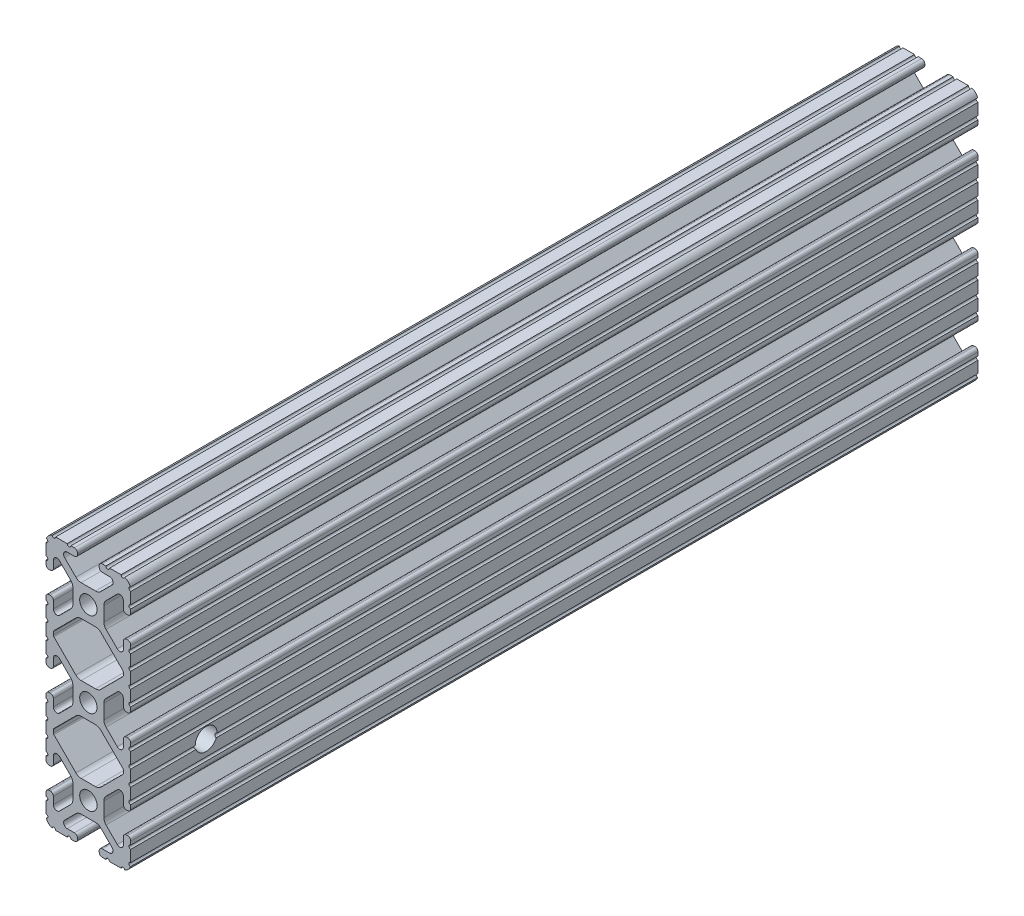
from build123d import *

# Parameters (mm, degrees)
BOSS_EXTRUDE1_DEPTH     = 127
SKETCH5_R               = 0.55245
CUT_EXTRUDE1_DEPTH      = 134.198723718
CUT_EXTRUDE1_DEPTH_BACK = 134.198723718
BOSS_EXTRUDE2_DEPTH     = 127
CUT_EXTRUDE2_DEPTH      = 134.198723718
CUT_EXTRUDE2_DEPTH_BACK = 134.198723718
SKETCH8_R               = 3.2639
CUT_EXTRUDE3_DEPTH      = 136.002851822


with BuildPart() as part:
    # Sketch4 → Boss-Extrude1 (new, symmetric)
    with BuildSketch(Plane.XY):
        with BuildLine():
            Line((4.190365, -38.1), (10.11729625, -38.1))
            ThreePointArc((10.11729625, -38.1), (11.943543585, -37.343543585), (12.7, -35.51729625))
            Line((12.7, -35.51729625), (12.7, -29.590365))
            ThreePointArc((12.7, -29.590365), (12.42492494, -28.92627506), (11.760835, -28.6512))
            Line((11.760835, -28.6512), (11.429365, -28.6512))
            ThreePointArc((11.429365, -28.6512), (10.76527506, -28.92627506), (10.4902, -29.590365))
            Line((10.4902, -29.590365), (10.4902, -31.748478019))
            ThreePointArc((10.4902, -31.748478019), (9.830707141, -32.735478831), (8.666460301, -32.503895736))
            Line((8.666460301, -32.503895736), (5.299899128, -29.137334563))
            ThreePointArc((5.299899128, -29.137334563), (4.817571085, -28.415479634), (4.6482, -27.56399369))
            Line((4.6482, -27.56399369), (4.6482, -25.4))
            Line((4.6482, -25.4), (2.6035, -25.4))
            ThreePointArc((2.6035, -25.4), (1.840952505, -27.240952505), (0, -28.0035))
            Line((0, -28.0035), (0, -30.0482))
            Line((0, -30.0482), (2.16399369, -30.0482))
            ThreePointArc((2.16399369, -30.0482), (3.015479634, -30.217571085), (3.737334563, -30.699899128))
            Line((3.737334563, -30.699899128), (7.103895736, -34.066460301))
            ThreePointArc((7.103895736, -34.066460301), (7.335478831, -35.230707141), (6.348478019, -35.8902))
            Line((6.348478019, -35.8902), (4.190365, -35.8902))
            ThreePointArc((4.190365, -35.8902), (3.52627506, -36.16527506), (3.2512, -36.829365))
            Line((3.2512, -36.829365), (3.2512, -37.160835))
            ThreePointArc((3.2512, -37.160835), (3.52627506, -37.82492494), (4.190365, -38.1))
        make_face()
    extrude(amount=BOSS_EXTRUDE1_DEPTH, both=True)

    # Sketch5 → Cut-Extrude1 (cut, two sides)
    with BuildSketch(Plane.XY) as cut_extrude1_sk:
        with Locations((10.356153152, -38.1)):
            Circle(SKETCH5_R)
        with Locations((5.796028019, -38.1)):
            Circle(SKETCH5_R)
        with Locations((12.7, -35.756153152)):
            Circle(SKETCH5_R)
        with Locations((12.7, -31.196028019)):
            Circle(SKETCH5_R)
    extrude(amount=CUT_EXTRUDE1_DEPTH, mode=Mode.SUBTRACT)
    extrude(cut_extrude1_sk.sketch, amount=-CUT_EXTRUDE1_DEPTH_BACK, mode=Mode.SUBTRACT)

    # Mirror1: part across plane


with BuildPart() as part_1:
    add(part.part)
    add(part.part.mirror(Plane(origin=(4.6482, -25.4, 127), x_dir=(0, 0, 1), z_dir=(0, -1, 0))))

    # Sketch6 → Boss-Extrude2 (add, symmetric)
    with BuildSketch(Plane.XY):
        with BuildLine():
            Line((12.7, -14.491396848), (12.7, -12.7))
            Line((12.7, -12.7), (9.803703152, -12.7))
            Line((9.803703152, -12.7), (9.803703152, -15.596296848))
            Line((9.803703152, -15.596296848), (12.7, -15.596296848))
            ThreePointArc((12.7, -15.596296848), (12.14755, -15.043846848), (12.7, -14.491396848))
        make_face()
    extrude(amount=BOSS_EXTRUDE2_DEPTH, both=True)

    # Sketch7 → Cut-Extrude2 (cut, two sides)
    with BuildSketch(Plane.XY) as cut_extrude2_sk:
        with BuildLine():
            Line((5.420615149, -18.416820286), (10.328391141, -13.509044294))
            ThreePointArc((10.328391141, -13.509044294), (10.448147248, -13.329816615), (10.4902, -13.118403152))
            Line((10.4902, -13.118403152), (10.4902, -12.7))
            Line((10.4902, -12.7), (0, -12.7))
            Line((0, -12.7), (5.420615149, -18.416820286))
        make_face()
    extrude(amount=CUT_EXTRUDE2_DEPTH, mode=Mode.SUBTRACT)
    extrude(cut_extrude2_sk.sketch, amount=-CUT_EXTRUDE2_DEPTH_BACK, mode=Mode.SUBTRACT)

    # Mirror2: part across plane


with BuildPart() as part_2:
    add(part_1.part)
    add(part_1.part.mirror(Plane(origin=(4.190365, -12.7, 127), x_dir=(0, 0, 1), z_dir=(0, -1, 0))))

    # SurfaceCut1
    split(bisect_by=Plane(origin=(0, 0, 0), x_dir=(1, 0, 0), z_dir=(0, 1, 0)), keep=Keep.BOTTOM)

    # Mirror3: part across plane


with BuildPart() as part_3:
    add(part_2.part)
    add(part_2.part.mirror(Plane(origin=(0, 0, 0), x_dir=(0, 0, 1), z_dir=(1, 0, 0))))

    # Mirror4: part across plane


with BuildPart() as part_4:
    add(part_3.part)
    add(part_3.part.mirror(Plane.ZX))

    # Sketch8 → Cut-Extrude3 (cut, through all)
    with BuildSketch(Plane.ZY.offset(12.7)):
        with Locations(Location((104.4, -14.4, 0), (0, 0, 358.395374172))):
            Circle(SKETCH8_R)
    extrude(amount=-CUT_EXTRUDE3_DEPTH, mode=Mode.SUBTRACT)


solid = part_4.part
